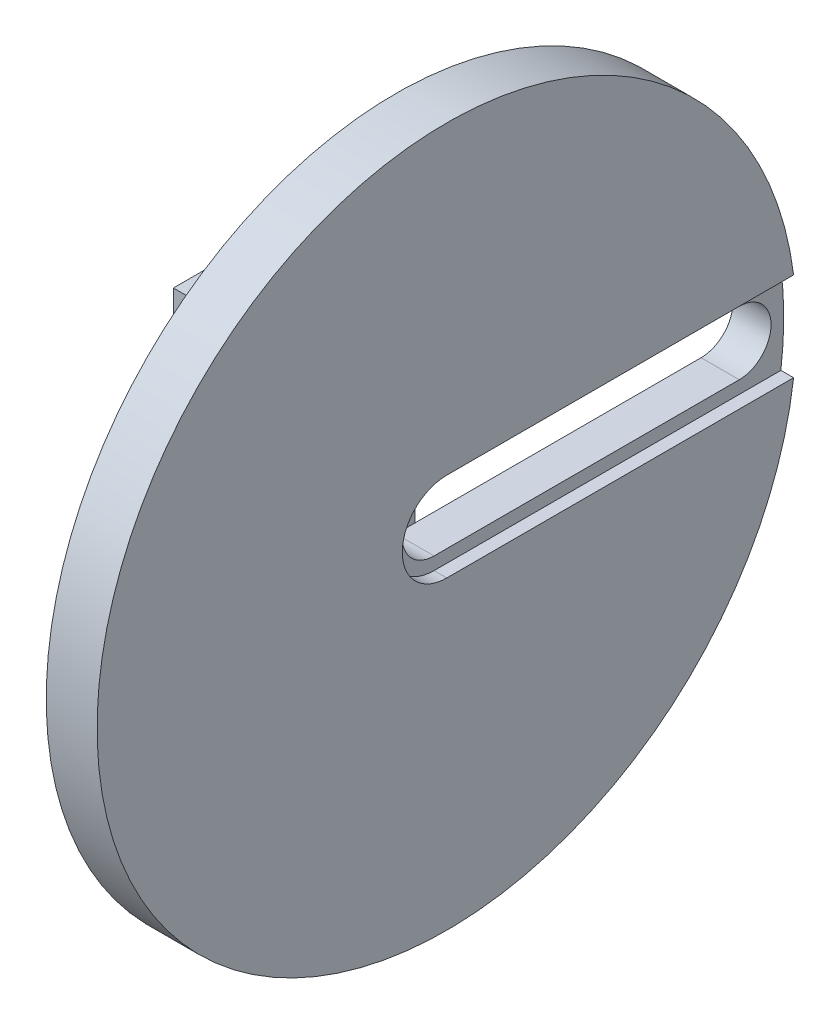
from build123d import *

# Parameters (mm, degrees)
SKETCH_1_R          = 7.5
EXTRUDE_1_DEPTH     = 10
SKETCH_5_W          = 30
SKETCH_5_H          = 52
EXTRUDE_2_DEPTH     = 8
SKETCH_6_W          = 30
SKETCH_6_H          = 8
EXTRUDE_3_DEPTH     = 12
SKETCH_7_R          = 55
EXTRUDE_4_DEPTH     = 8
CUT_EXTRUDE_4_REACH = 40
CUT_EXTRUDE_6_DEPTH = 2
CUT_EXTRUDE_7_REACH = 40
SKETCH_12_R         = 9


with BuildPart() as part:
    # 草图1 → 凸台-拉伸1 (new body)
    with BuildSketch(Plane(origin=(0, 0, 0), x_dir=(0, 0, -1), z_dir=(1, 0, 0))):
        Circle(SKETCH_1_R)
    extrude(amount=EXTRUDE_1_DEPTH)

    # 草图5 → 凸台-拉伸2 (add)
    with BuildSketch(Plane(origin=(10, 0, 0), x_dir=(0, 0, -1), z_dir=(1, 0, 0))):
        Rectangle(SKETCH_5_W, SKETCH_5_H)
    extrude(amount=EXTRUDE_2_DEPTH)

    # 草图6 → 凸台-拉伸3 (add)
    with BuildSketch(Plane(origin=(18, 0, 0), x_dir=(0, 0, -1), z_dir=(1, 0, 0))):
        with Locations((0, 22)):
            Rectangle(SKETCH_6_W, SKETCH_6_H)
        with Locations((0, -22)):
            Rectangle(SKETCH_6_W, SKETCH_6_H)
    extrude(amount=EXTRUDE_3_DEPTH)

    # 草图7 → 凸台-拉伸4 (add)
    with BuildSketch(Plane(origin=(30, 0, 0), x_dir=(0, 0, -1), z_dir=(1, 0, 0))):
        Circle(SKETCH_7_R)
    extrude(amount=EXTRUDE_4_DEPTH)

    # 草图8 → 切除-拉伸4 (cut, up to next)
    with BuildSketch(Plane(origin=(38, 0, 0), x_dir=(0, 0, -1), z_dir=(1, 0, 0)), mode=Mode.PRIVATE) as cut_extrude_4_sk1:
        with BuildLine():
            Line((0, 5), (48, 5))
            ThreePointArc((48, 5), (53, 0), (48, -5))
            Line((48, -5), (0, -5))
            ThreePointArc((0, -5), (-5, 0), (0, 5))
        make_face()
    cut_extrude_4_tool1 = extrude(cut_extrude_4_sk1.sketch, amount=-CUT_EXTRUDE_4_REACH, mode=Mode.PRIVATE) & part.part
    add(cut_extrude_4_tool1.solids().sort_by_distance((38, 0, -24))[0], mode=Mode.SUBTRACT)

    # 草图11 → 切除-拉伸6 (cut)
    with BuildSketch(Plane(origin=(38, 0, 0), x_dir=(0, 0, -1), z_dir=(1, 0, 0))):
        with BuildLine():
            Line((0, 7), (54.552726788, 7))
            ThreePointArc((54.552726788, 7), (55, 0), (54.552726788, -7))
            Line((54.552726788, -7), (0, -7))
            ThreePointArc((0, -7), (-7, 0), (0, 7))
        make_face()
    extrude(amount=-CUT_EXTRUDE_6_DEPTH, mode=Mode.SUBTRACT)

    # 草图12 → 切除-拉伸7 (cut, up to next)
    with BuildSketch(Plane.ZY, mode=Mode.PRIVATE) as cut_extrude_7_sk1:
        Circle(SKETCH_12_R)
    cut_extrude_7_tool1 = extrude(cut_extrude_7_sk1.sketch, amount=-CUT_EXTRUDE_7_REACH, mode=Mode.PRIVATE) & part.part
    add(cut_extrude_7_tool1.solids().sort_by_distance((0, 0, 0))[0], mode=Mode.SUBTRACT)


solid = part.part
